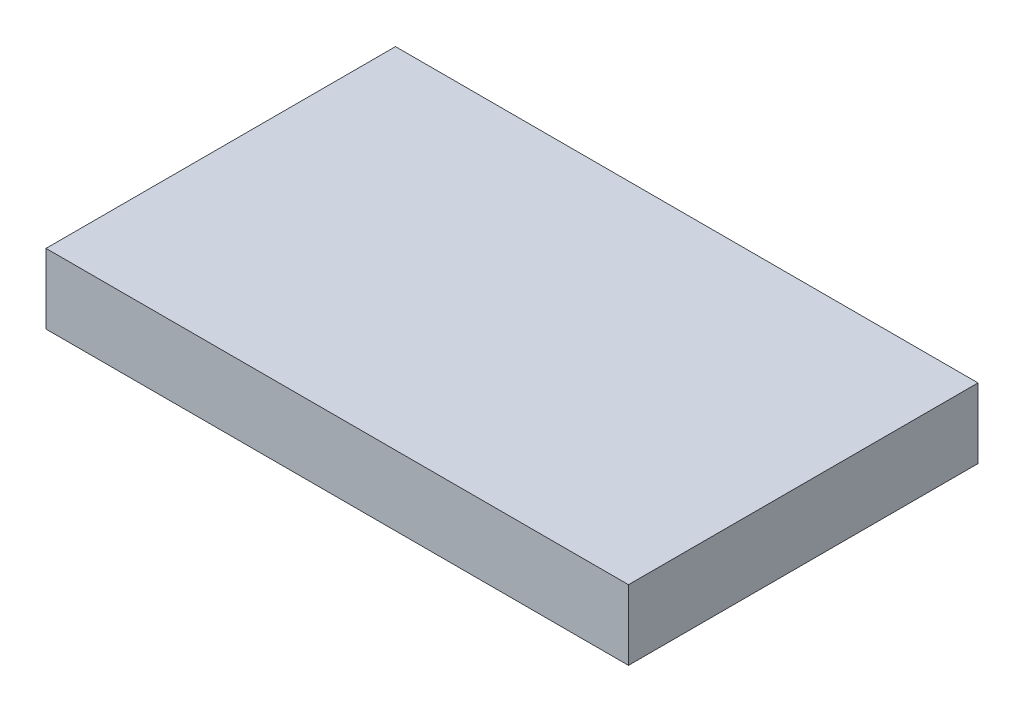
from build123d import *

# Parameters (mm, degrees)
SKETCH1_W           = 50
SKETCH1_H           = 30
BOSS_EXTRUDE1_DEPTH = 6


with BuildPart() as part:
    # Sketch1 → Boss-Extrude1 (new body)
    with BuildSketch(Plane(origin=(0, 0, 0), x_dir=(1, 0, 0), z_dir=(0, 1, 0))):
        Rectangle(SKETCH1_W, SKETCH1_H)
    extrude(amount=BOSS_EXTRUDE1_DEPTH)


solid = part.part
